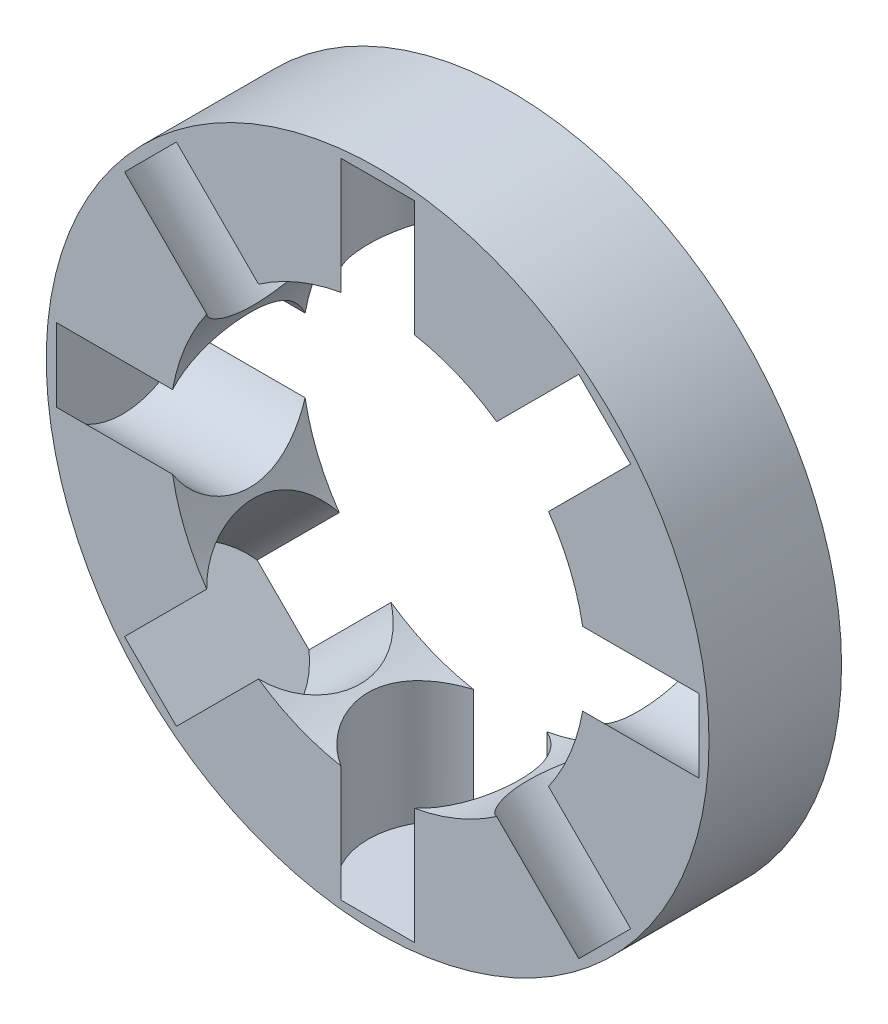
from build123d import *

# Parameters (mm, degrees)
SKETCH1_R           = 17.5
SKETCH1_R_2         = 11
BOSS_EXTRUDE1_DEPTH = 3.5
SKETCH4_R           = 4
CUT_EXTRUDE1_DEPTH  = 6.8
CIRPATTERN1_COUNT   = 8


with BuildPart() as part:
    # Sketch1 → Boss-Extrude1 (new, symmetric)
    with BuildSketch(Plane.XY):
        Circle(SKETCH1_R)
        Circle(SKETCH1_R_2, mode=Mode.SUBTRACT)
    extrude(amount=BOSS_EXTRUDE1_DEPTH, both=True)

    # Sketch4 → Cut-Extrude1 (cut)
    with BuildSketch(Plane(origin=(-10.162674858, 0, 0), x_dir=(0, 0, -1), z_dir=(1, 0, 0))):
        Circle(SKETCH4_R)
    cut_extrude1 = extrude(amount=-CUT_EXTRUDE1_DEPTH, mode=Mode.SUBTRACT)

    # CirPattern1: Cut-Extrude1 ×8 about axis
    cirpattern1_axis = Axis((0, 0, 3.5), (0, 0, -1))
    for i in range(1, CIRPATTERN1_COUNT):
        add(cut_extrude1.rotate(cirpattern1_axis, i * 360 / CIRPATTERN1_COUNT), mode=Mode.SUBTRACT)


solid = part.part
